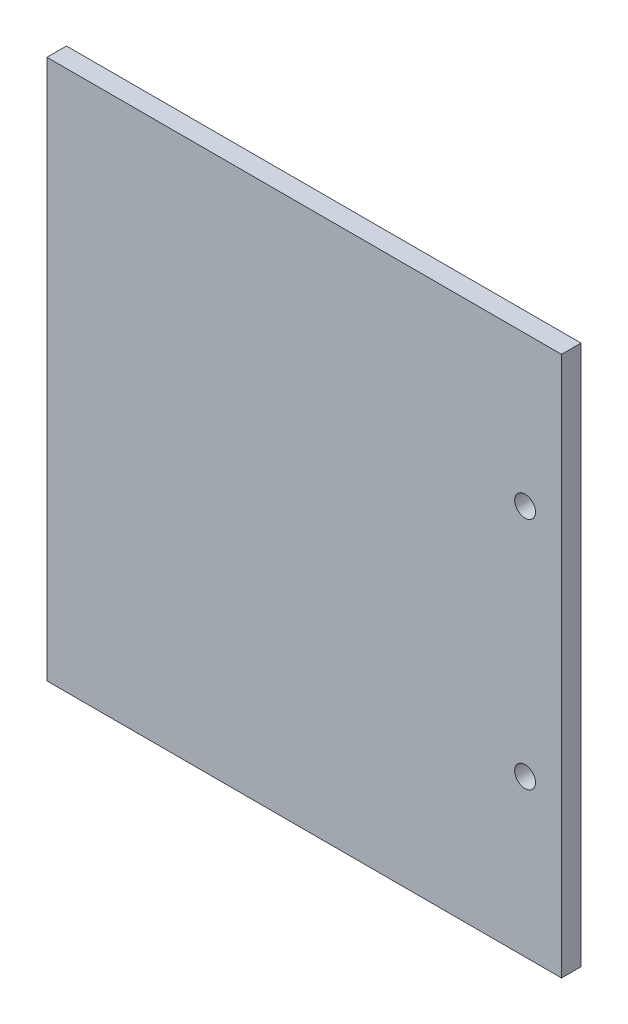
from build123d import *

# Parameters (mm, degrees)
SKETCH1_W           = 125.542000122
SKETCH1_H           = 131.7625
SKETCH1_R           = 2.54
BOSS_EXTRUDE1_DEPTH = 4.7625


with BuildPart() as part:
    # Sketch1 → Boss-Extrude1 (new body)
    with BuildSketch(Plane.XY):
        with Locations((79.468999939, 65.88125)):
            Rectangle(SKETCH1_W, SKETCH1_H)
        with Locations((133.35, 38.1)):
            Circle(SKETCH1_R, mode=Mode.SUBTRACT)
        with Locations((133.35, 95.25)):
            Circle(SKETCH1_R, mode=Mode.SUBTRACT)
    extrude(amount=BOSS_EXTRUDE1_DEPTH)


solid = part.part
